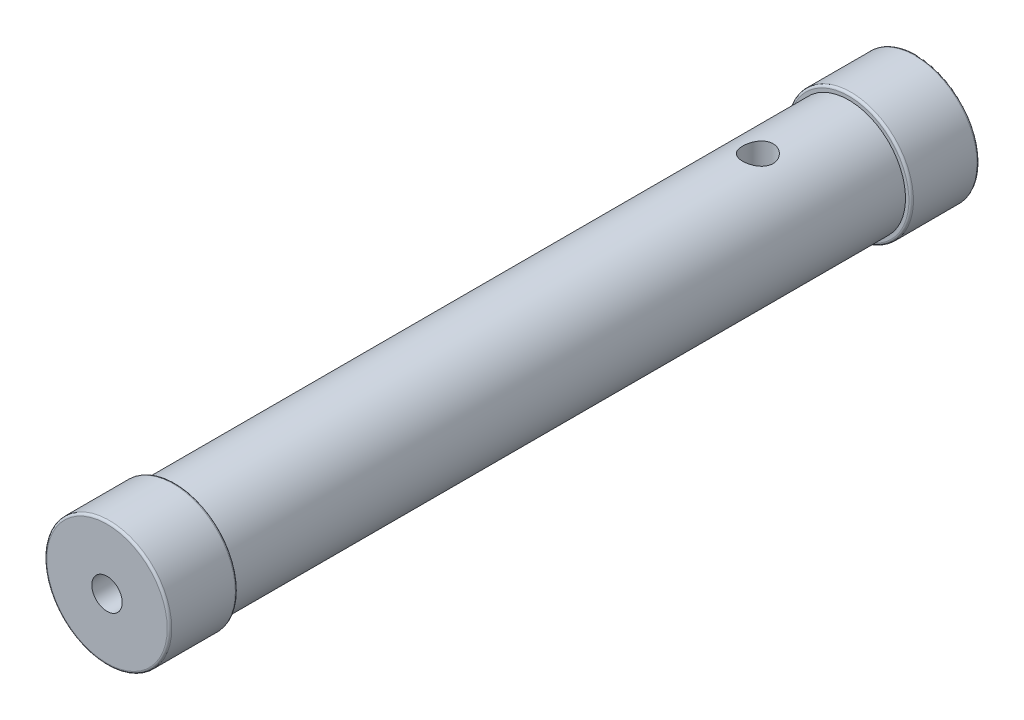
from build123d import *

# Parameters (mm, degrees)
SKETCH1_R           = 25
BOSS_EXTRUDE1_DEPTH = 356.5
SKETCH2_R           = 27.5
BOSS_EXTRUDE2_DEPTH = 30
SKETCH3_R           = 27.5
BOSS_EXTRUDE3_DEPTH = 30
SKETCH4_R           = 6.7
CUT_EXTRUDE1_DEPTH  = 20
SKETCH5_R           = 6.7
CUT_EXTRUDE2_DEPTH  = 20
SKETCH6_R           = 6.7
CUT_EXTRUDE3_DEPTH  = 20
FILLET1_R           = 1


with BuildPart() as part:
    # Sketch1 → Boss-Extrude1 (new body)
    with BuildSketch(Plane(origin=(0, 0, 0), x_dir=(0, 1, 0), z_dir=(0, 0, 1))):
        Circle(SKETCH1_R)
    extrude(amount=BOSS_EXTRUDE1_DEPTH)

    # Sketch2 → Boss-Extrude2 (add)
    with BuildSketch(Plane.XY.offset(356.5)):
        Circle(SKETCH2_R)
    extrude(amount=-BOSS_EXTRUDE2_DEPTH)

    # Sketch3 → Boss-Extrude3 (add)
    with BuildSketch(Plane(origin=(0, 0, 0), x_dir=(-1, 0, 0), z_dir=(0, 0, -1))):
        Circle(SKETCH3_R)
    extrude(amount=-BOSS_EXTRUDE3_DEPTH)

    # Sketch4 → Cut-Extrude1 (cut)
    with BuildSketch(Plane(origin=(0, 0, 0), x_dir=(1, 0, 0), z_dir=(0, 0, -1))):
        Circle(SKETCH4_R)
    extrude(amount=-CUT_EXTRUDE1_DEPTH, mode=Mode.SUBTRACT)

    # Sketch5 → Cut-Extrude2 (cut)
    with BuildSketch(Plane.XY.offset(356.5)):
        Circle(SKETCH5_R)
    extrude(amount=-CUT_EXTRUDE2_DEPTH, mode=Mode.SUBTRACT)

    # Sketch6 → Cut-Extrude3 (cut)
    with BuildSketch(Plane(origin=(0, 25, 0), x_dir=(-1, 0, 0), z_dir=(0, 1, 0))):
        with Locations((0, 70)):
            Circle(SKETCH6_R)
    extrude(amount=-CUT_EXTRUDE3_DEPTH, mode=Mode.SUBTRACT)

    # Fillet1
    fillet1_edges = [part.edges().sort_by_distance(p)[0] for p in [
        (27.5, 0, 30),
        (27.5, 0, 0),
        (-27.5, 0, 326.5),
        (-27.5, 0, 356.5),
    ]]
    fillet(fillet1_edges, radius=FILLET1_R)


solid = part.part
